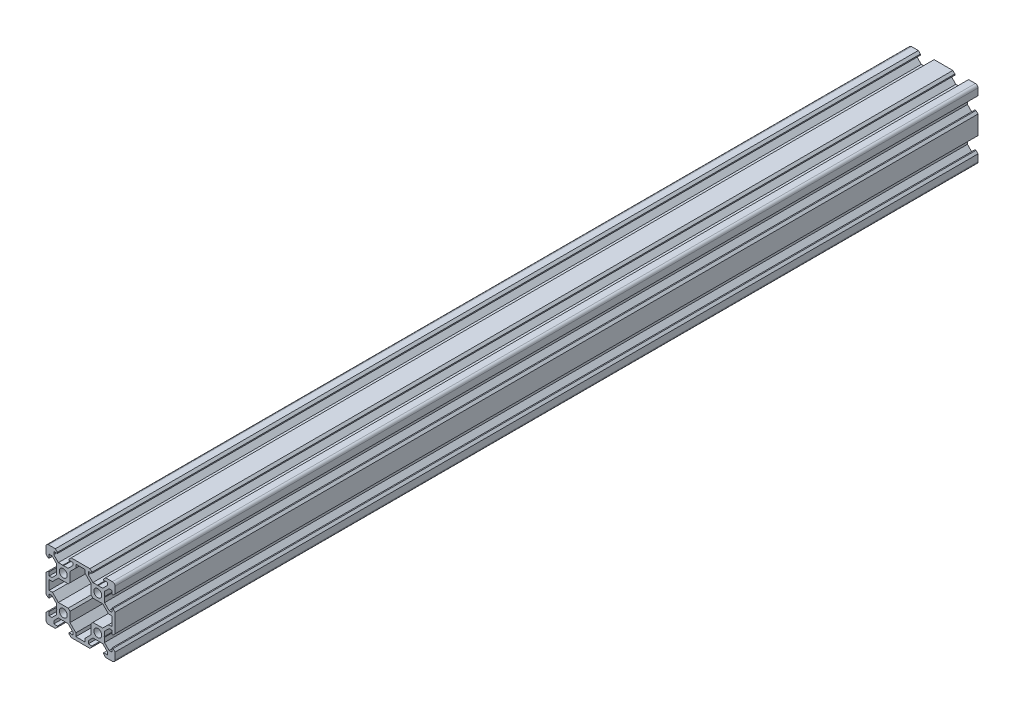
from build123d import *

# Parameters (mm, degrees)
SKETCH1_R           = 2.3
BOSS_EXTRUDE1_DEPTH = 500


with BuildPart() as part:
    # Sketch1 → Boss-Extrude1 (new body)
    with BuildSketch(Plane.XY):
        with BuildLine():
            Line((13.69, -10), (13.9, -10.21))
            Line((13.9, -10.21), (13.9, -12.839339828))
            Line((13.9, -12.839339828), (16.560660172, -15.5))
            Line((16.560660172, -15.5), (18.2, -15.5))
            Line((18.2, -15.5), (18.2, -13.395))
            Line((18.2, -13.395), (18.815, -13.395))
            Line((18.815, -13.395), (20, -14.58))
            Line((20, -14.58), (20, -18.5))
            ThreePointArc((20, -18.5), (19.560660172, -19.560660172), (18.5, -20))
            Line((18.5, -20), (14.58, -20))
            Line((14.58, -20), (13.395, -18.815))
            Line((13.395, -18.815), (13.395, -18.2))
            Line((13.395, -18.2), (15.5, -18.2))
            Line((15.5, -18.2), (15.5, -16.560660172))
            Line((15.5, -16.560660172), (12.839339828, -13.9))
            Line((12.839339828, -13.9), (10.21, -13.9))
            Line((10.21, -13.9), (10, -13.69))
            Line((10, -13.69), (9.79, -13.9))
            Line((9.79, -13.9), (7.160660172, -13.9))
            Line((7.160660172, -13.9), (4.5, -16.560660172))
            Line((4.5, -16.560660172), (4.5, -18.2))
            Line((4.5, -18.2), (6.605, -18.2))
            Line((6.605, -18.2), (6.605, -18.815))
            Line((6.605, -18.815), (5.42, -20))
            Line((5.42, -20), (-5.42, -20))
            Line((-5.42, -20), (-6.605, -18.815))
            Line((-6.605, -18.815), (-6.605, -18.2))
            Line((-6.605, -18.2), (-4.5, -18.2))
            Line((-4.5, -18.2), (-4.5, -16.560660172))
            Line((-4.5, -16.560660172), (-7.160660172, -13.9))
            Line((-7.160660172, -13.9), (-9.79, -13.9))
            Line((-9.79, -13.9), (-10, -13.69))
            Line((-10, -13.69), (-10.21, -13.9))
            Line((-10.21, -13.9), (-12.839339828, -13.9))
            Line((-12.839339828, -13.9), (-15.5, -16.560660172))
            Line((-15.5, -16.560660172), (-15.5, -18.2))
            Line((-15.5, -18.2), (-13.395, -18.2))
            Line((-13.395, -18.2), (-13.395, -18.815))
            Line((-13.395, -18.815), (-14.58, -20))
            Line((-14.58, -20), (-18.5, -20))
            ThreePointArc((-18.5, -20), (-19.560660172, -19.560660172), (-20, -18.5))
            Line((-20, -18.5), (-20, -14.58))
            Line((-20, -14.58), (-18.815, -13.395))
            Line((-18.815, -13.395), (-18.2, -13.395))
            Line((-18.2, -13.395), (-18.2, -15.5))
            Line((-18.2, -15.5), (-16.560660172, -15.5))
            Line((-16.560660172, -15.5), (-13.9, -12.839339828))
            Line((-13.9, -12.839339828), (-13.9, -10.21))
            Line((-13.9, -10.21), (-13.69, -10))
            Line((-13.69, -10), (-13.9, -9.79))
            Line((-13.9, -9.79), (-13.9, -7.160660172))
            Line((-13.9, -7.160660172), (-16.560660172, -4.5))
            Line((-16.560660172, -4.5), (-18.2, -4.5))
            Line((-18.2, -4.5), (-18.2, -6.605))
            Line((-18.2, -6.605), (-18.815, -6.605))
            Line((-18.815, -6.605), (-20, -5.42))
            Line((-20, -5.42), (-20, 5.42))
            Line((-20, 5.42), (-18.815, 6.605))
            Line((-18.815, 6.605), (-18.2, 6.605))
            Line((-18.2, 6.605), (-18.2, 4.5))
            Line((-18.2, 4.5), (-16.560660172, 4.5))
            Line((-16.560660172, 4.5), (-13.9, 7.160660172))
            Line((-13.9, 7.160660172), (-13.9, 9.79))
            Line((-13.9, 9.79), (-13.69, 10))
            Line((-13.69, 10), (-13.9, 10.21))
            Line((-13.9, 10.21), (-13.9, 12.839339828))
            Line((-13.9, 12.839339828), (-16.560660172, 15.5))
            Line((-16.560660172, 15.5), (-18.2, 15.5))
            Line((-18.2, 15.5), (-18.2, 13.395))
            Line((-18.2, 13.395), (-18.815, 13.395))
            Line((-18.815, 13.395), (-20, 14.58))
            Line((-20, 14.58), (-20, 18.5))
            ThreePointArc((-20, 18.5), (-19.560660172, 19.560660172), (-18.5, 20))
            Line((-18.5, 20), (-14.58, 20))
            Line((-14.58, 20), (-13.395, 18.815))
            Line((-13.395, 18.815), (-13.395, 18.2))
            Line((-13.395, 18.2), (-15.5, 18.2))
            Line((-15.5, 18.2), (-15.5, 16.560660172))
            Line((-15.5, 16.560660172), (-12.839339828, 13.9))
            Line((-12.839339828, 13.9), (-10.21, 13.9))
            Line((-10.21, 13.9), (-10, 13.69))
            Line((-10, 13.69), (-9.79, 13.9))
            Line((-9.79, 13.9), (-7.160660172, 13.9))
            Line((-7.160660172, 13.9), (-4.5, 16.560660172))
            Line((-4.5, 16.560660172), (-4.5, 18.2))
            Line((-4.5, 18.2), (-6.605, 18.2))
            Line((-6.605, 18.2), (-6.605, 18.815))
            Line((-6.605, 18.815), (-5.42, 20))
            Line((-5.42, 20), (5.42, 20))
            Line((5.42, 20), (6.605, 18.815))
            Line((6.605, 18.815), (6.605, 18.2))
            Line((6.605, 18.2), (4.5, 18.2))
            Line((4.5, 18.2), (4.5, 16.560660172))
            Line((4.5, 16.560660172), (7.160660172, 13.9))
            Line((7.160660172, 13.9), (9.79, 13.9))
            Line((9.79, 13.9), (10, 13.69))
            Line((10, 13.69), (10.21, 13.9))
            Line((10.21, 13.9), (12.839339828, 13.9))
            Line((12.839339828, 13.9), (15.5, 16.560660172))
            Line((15.5, 16.560660172), (15.5, 18.2))
            Line((15.5, 18.2), (13.395, 18.2))
            Line((13.395, 18.2), (13.395, 18.815))
            Line((13.395, 18.815), (14.58, 20))
            Line((14.58, 20), (18.5, 20))
            ThreePointArc((18.5, 20), (19.560660172, 19.560660172), (20, 18.5))
            Line((20, 18.5), (20, 14.58))
            Line((20, 14.58), (18.815, 13.395))
            Line((18.815, 13.395), (18.2, 13.395))
            Line((18.2, 13.395), (18.2, 15.5))
            Line((18.2, 15.5), (16.560660172, 15.5))
            Line((16.560660172, 15.5), (13.9, 12.839339828))
            Line((13.9, 12.839339828), (13.9, 10.21))
            Line((13.9, 10.21), (13.69, 10))
            Line((13.69, 10), (13.9, 9.79))
            Line((13.9, 9.79), (13.9, 7.160660172))
            Line((13.9, 7.160660172), (16.560660172, 4.5))
            Line((16.560660172, 4.5), (18.2, 4.5))
            Line((18.2, 4.5), (18.2, 6.605))
            Line((18.2, 6.605), (18.815, 6.605))
            Line((18.815, 6.605), (20, 5.42))
            Line((20, 5.42), (20, -5.42))
            Line((20, -5.42), (18.815, -6.605))
            Line((18.815, -6.605), (18.2, -6.605))
            Line((18.2, -6.605), (18.2, -4.5))
            Line((18.2, -4.5), (16.560660172, -4.5))
            Line((16.560660172, -4.5), (13.9, -7.160660172))
            Line((13.9, -7.160660172), (13.9, -9.79))
            Line((13.9, -9.79), (13.69, -10))
        make_face()
        with Locations((-10, -10)):
            Circle(SKETCH1_R, mode=Mode.SUBTRACT)
        with Locations((10, 10)):
            Circle(SKETCH1_R, mode=Mode.SUBTRACT)
        with Locations((-10, 10)):
            Circle(SKETCH1_R, mode=Mode.SUBTRACT)
        with Locations((10, -10)):
            Circle(SKETCH1_R, mode=Mode.SUBTRACT)
        Polygon((-6.1, -12.839339828), (-6.1, -7.160660172), (-7.160660172, -6.1), (-12.839339828, -6.1), (-16.239339828, -2.7), (-18.2, -2.7), (-18.2, 2.7), (-16.239339828, 2.7), (-12.839339828, 6.1), (-7.160660172, 6.1), (-6.1, 7.160660172), (-6.1, 12.839339828), (-2.7, 16.239339828), (-2.7, 18.2), (2.7, 18.2), (2.7, 16.239339828), (6.1, 12.839339828), (6.1, 7.160660172), (7.160660172, 6.1), (12.839339828, 6.1), (16.239339828, 2.7), (18.2, 2.7), (18.2, -2.7), (16.239339828, -2.7), (12.839339828, -6.1), (7.160660172, -6.1), (6.1, -7.160660172), (6.1, -12.839339828), (2.7, -16.239339828), (2.7, -18.2), (-2.7, -18.2), (-2.7, -16.239339828), align=None, mode=Mode.SUBTRACT)
    extrude(amount=BOSS_EXTRUDE1_DEPTH)


solid = part.part
